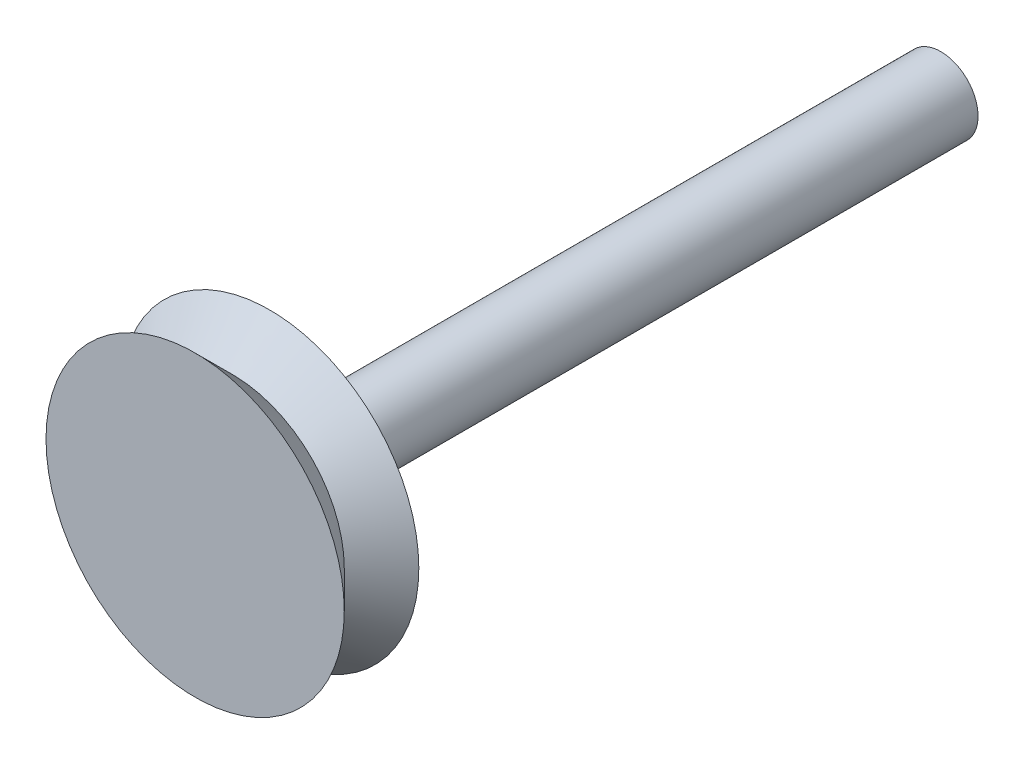
from build123d import *

# Parameters (mm, degrees)
SKETCH1_R           = 4
BOSS_EXTRUDE1_DEPTH = 2
SKETCH2_R           = 1
BOSS_EXTRUDE2_DEPTH = 18


with BuildPart() as part:
    # Sketch1 → Boss-Extrude1 (new body)
    with BuildSketch(Plane.XY):
        Circle(SKETCH1_R)
    extrude(amount=BOSS_EXTRUDE1_DEPTH)

    # Sketch2 → Boss-Extrude2 (add)
    with BuildSketch(Plane(origin=(0, 0, 0), x_dir=(-1, 0, 0), z_dir=(0, 0, -1))):
        Circle(SKETCH2_R)
    extrude(amount=BOSS_EXTRUDE2_DEPTH)

    # Sketch3 → Cut-Revolve1 (revolve, cut)
    with BuildSketch(Plane(origin=(0, 0, 0), x_dir=(0, 0, -1), z_dir=(1, 0, 0))):
        Polygon((-2, 4), (-1, 3), (0, 4), align=None)
    revolve(axis=Axis((0, 0, 3.115097116), (0, 0, -1)), mode=Mode.SUBTRACT)


solid = part.part
